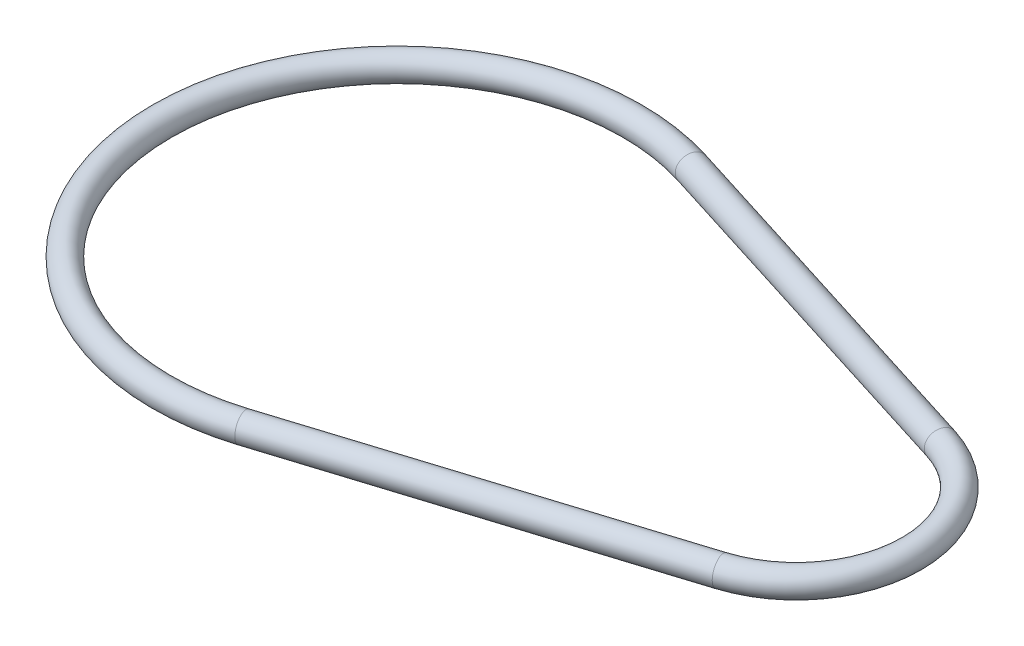
from build123d import *

# Parameters (mm, degrees)
SWEEP_1_PROFILE_R = 1.5


with BuildPart() as part:
    # 扫描1: sweep along a path in 草图1
    with BuildLine(Plane(origin=(0, 0, 0), x_dir=(1, 0, 0), z_dir=(0, 1, 0))) as sweep_1_path:
        Line((7.95, -25.279388838), (48.9, -12.401209618))
        ThreePointArc((48.9, -12.401209618), (58, 0), (48.9, 12.401209618))
        Line((48.9, 12.401209618), (7.95, 25.279388838))
        ThreePointArc((7.95, 25.279388838), (-26.5, 0), (7.95, -25.279388838))
    # 扫描1 profile (on start of the path) → 扫描1 (sweep)
    with BuildSketch(Plane(origin=(7.95, 0, 25.279388838), x_dir=(0.3, 0, 0.953939201), z_dir=(0.953939201, 0, -0.3))):
        Circle(SWEEP_1_PROFILE_R)
    sweep(path=sweep_1_path.line)


solid = part.part
